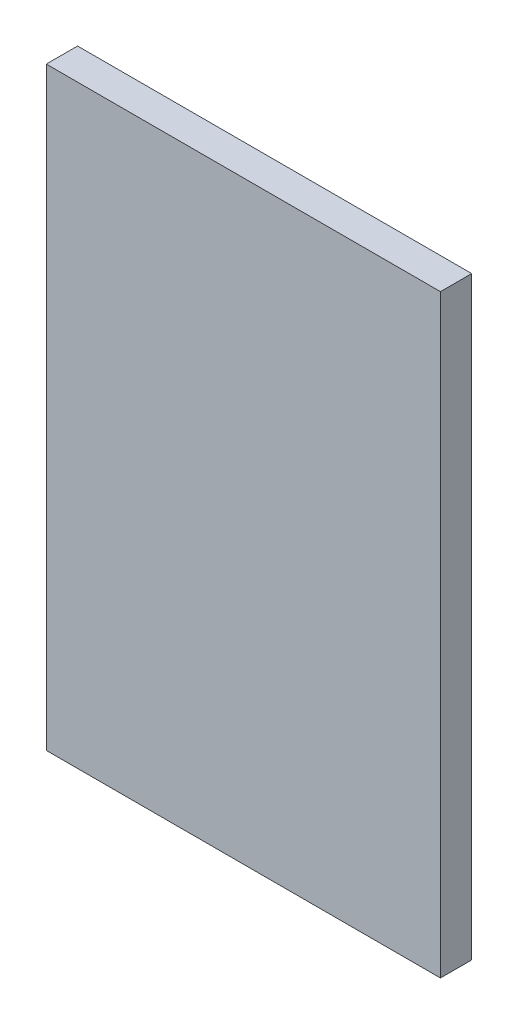
from build123d import *

# Parameters (mm, degrees)
SKETCH1_W           = 16.002
SKETCH1_H           = 24.13
BOSS_EXTRUDE1_DEPTH = 1.27


with BuildPart() as part:
    # Sketch1 → Boss-Extrude1 (new body)
    with BuildSketch(Plane.XY):
        Rectangle(SKETCH1_W, SKETCH1_H)
    extrude(amount=BOSS_EXTRUDE1_DEPTH)


solid = part.part
